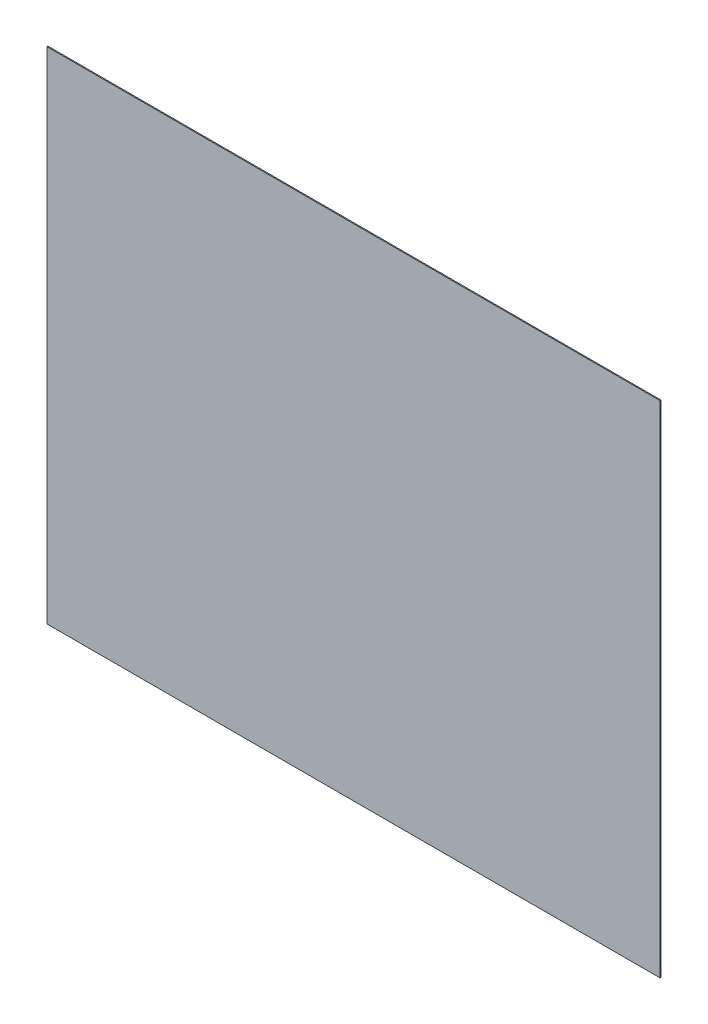
from build123d import *

# Parameters (mm, degrees)
CROQUIS1_W              = 1730
CROQUIS1_H              = 1410
SALIENTE_EXTRUIR1_DEPTH = 2.733


with BuildPart() as part:
    # Croquis1 → Saliente-Extruir1 (new body)
    with BuildSketch(Plane.XY):
        with Locations((865, 705)):
            Rectangle(CROQUIS1_W, CROQUIS1_H)
    extrude(amount=SALIENTE_EXTRUIR1_DEPTH)


solid = part.part
